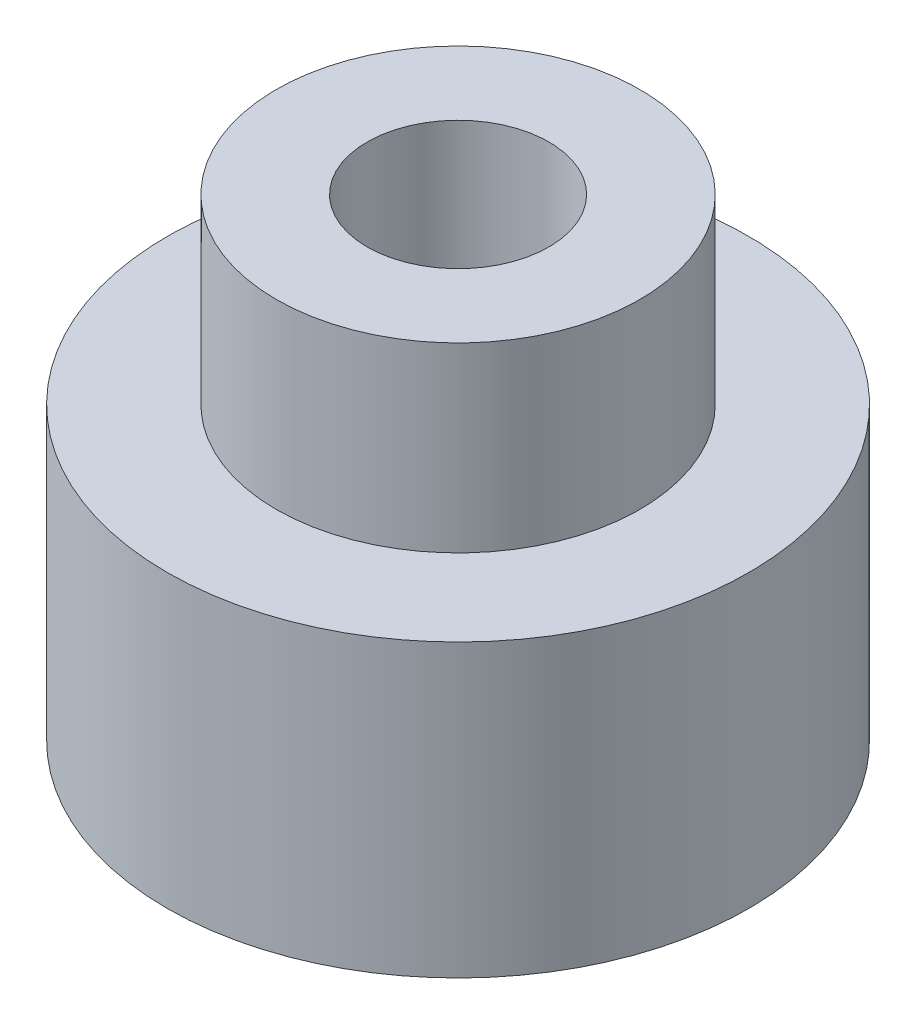
from build123d import *

# Parameters (mm, degrees)
ESQUISSE1_R             = 8
BOSS_EXTRU_1_DEPTH      = 8
ESQUISSE2_R             = 5
BOSS_EXTRU_2_DEPTH      = 5
ENL_V_MAT_EXTRU_1_REACH = 15
ESQUISSE3_R             = 2.5


with BuildPart() as part:
    # Esquisse1 → Boss.-Extru.1 (new body)
    with BuildSketch(Plane(origin=(0, 0, 0), x_dir=(1, 0, 0), z_dir=(0, 1, 0))):
        Circle(ESQUISSE1_R)
    extrude(amount=BOSS_EXTRU_1_DEPTH)

    # Esquisse2 → Boss.-Extru.2 (add)
    with BuildSketch(Plane(origin=(0, 8, 0), x_dir=(1, 0, 0), z_dir=(0, 1, 0))):
        Circle(ESQUISSE2_R)
    extrude(amount=BOSS_EXTRU_2_DEPTH)

    # Esquisse3 → Enlèv. mat.-Extru.1 (cut, up to next)
    with BuildSketch(Plane(origin=(0, 13, 0), x_dir=(1, 0, 0), z_dir=(0, 1, 0)), mode=Mode.PRIVATE) as enl_v_mat_extru_1_sk1:
        Circle(ESQUISSE3_R)
    enl_v_mat_extru_1_tool1 = extrude(enl_v_mat_extru_1_sk1.sketch, amount=-ENL_V_MAT_EXTRU_1_REACH, mode=Mode.PRIVATE) & part.part
    add(enl_v_mat_extru_1_tool1.solids().sort_by_distance((0, 13, 0))[0], mode=Mode.SUBTRACT)


solid = part.part
